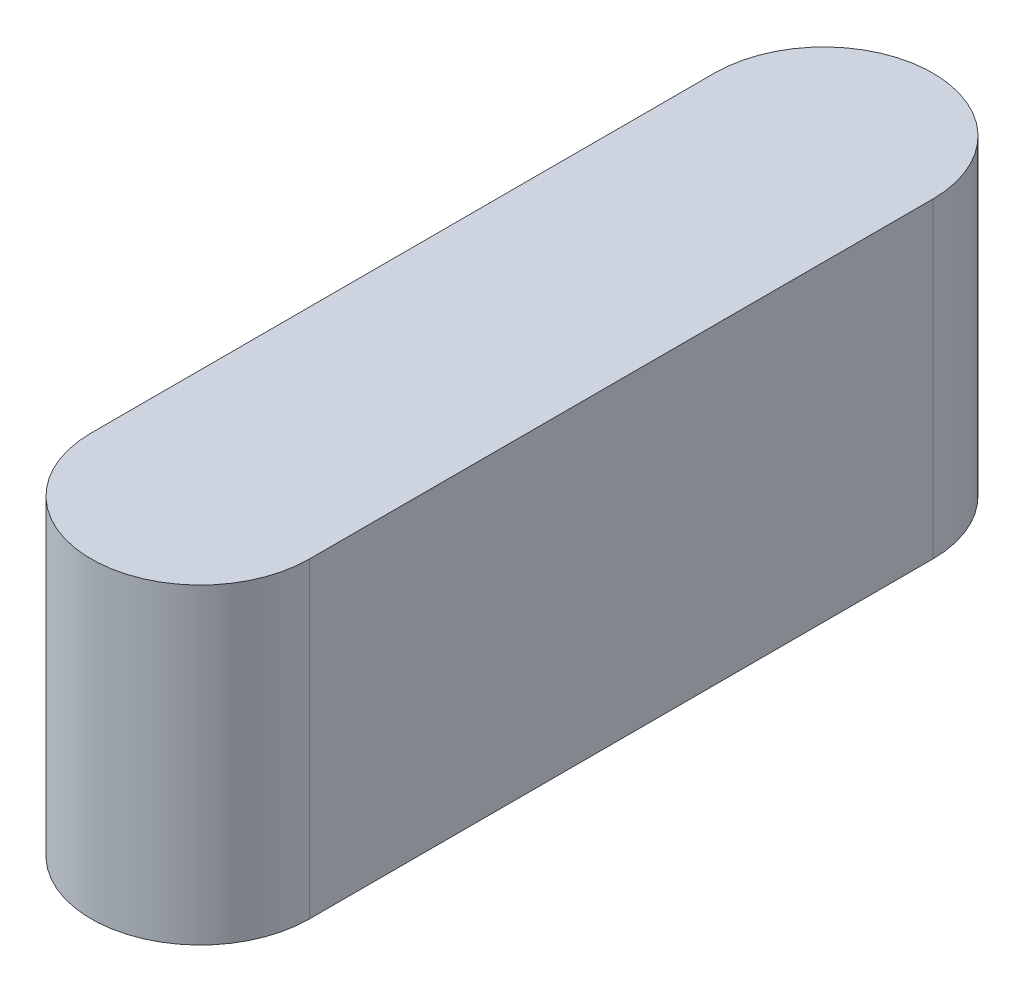
from build123d import *

# Parameters (mm, degrees)
BOSS_EXTRUDE1_DEPTH = 5


with BuildPart() as part:
    # Sketch3 → Boss-Extrude1 (new body)
    with BuildSketch(Plane(origin=(0, 0, 0), x_dir=(1, 0, 0), z_dir=(0, 1, 0))):
        with BuildLine():
            Line((1.75, -8.713994071), (1.75, -18.713994071))
            ThreePointArc((1.75, -18.713994071), (0, -20.463994071), (-1.75, -18.713994071))
            Line((-1.75, -18.713994071), (-1.75, -8.713994071))
            ThreePointArc((-1.75, -8.713994071), (0, -6.963994071), (1.75, -8.713994071))
        make_face()
    extrude(amount=BOSS_EXTRUDE1_DEPTH)


solid = part.part
